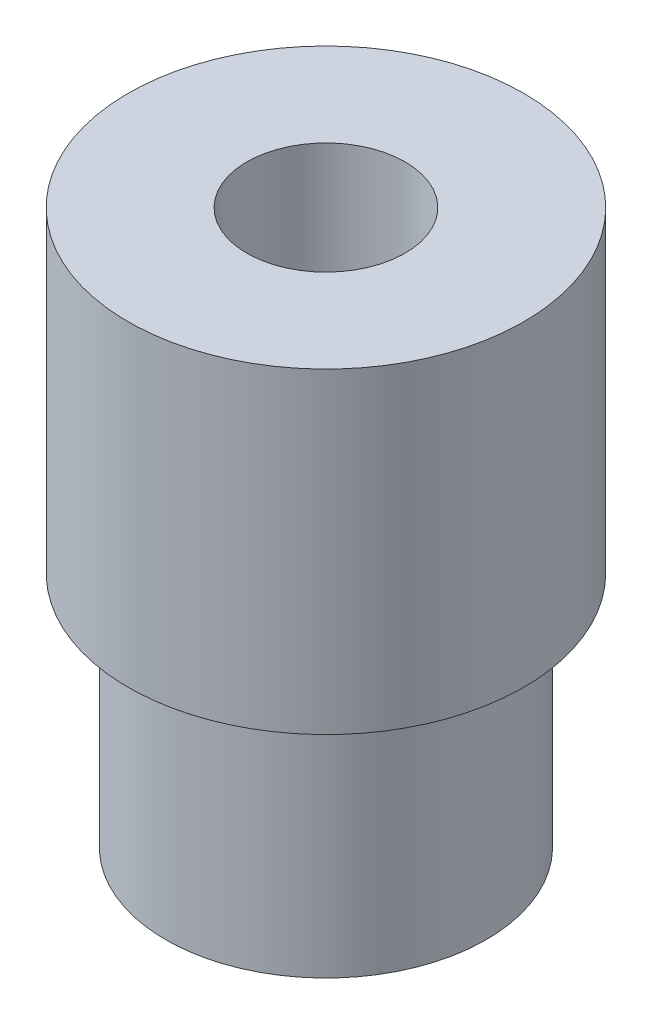
from build123d import *


with BuildPart() as part:
    # Esquisse1 → Révolution1 (revolve)
    with BuildSketch(Plane.XY):
        Polygon((2, 14), (5, 14), (5, 6), (4.05, 6), (4.05, 0), (2, 0), align=None)
    revolve(axis=Axis((0, 0, 0), (0, 1, 0)))


solid = part.part
